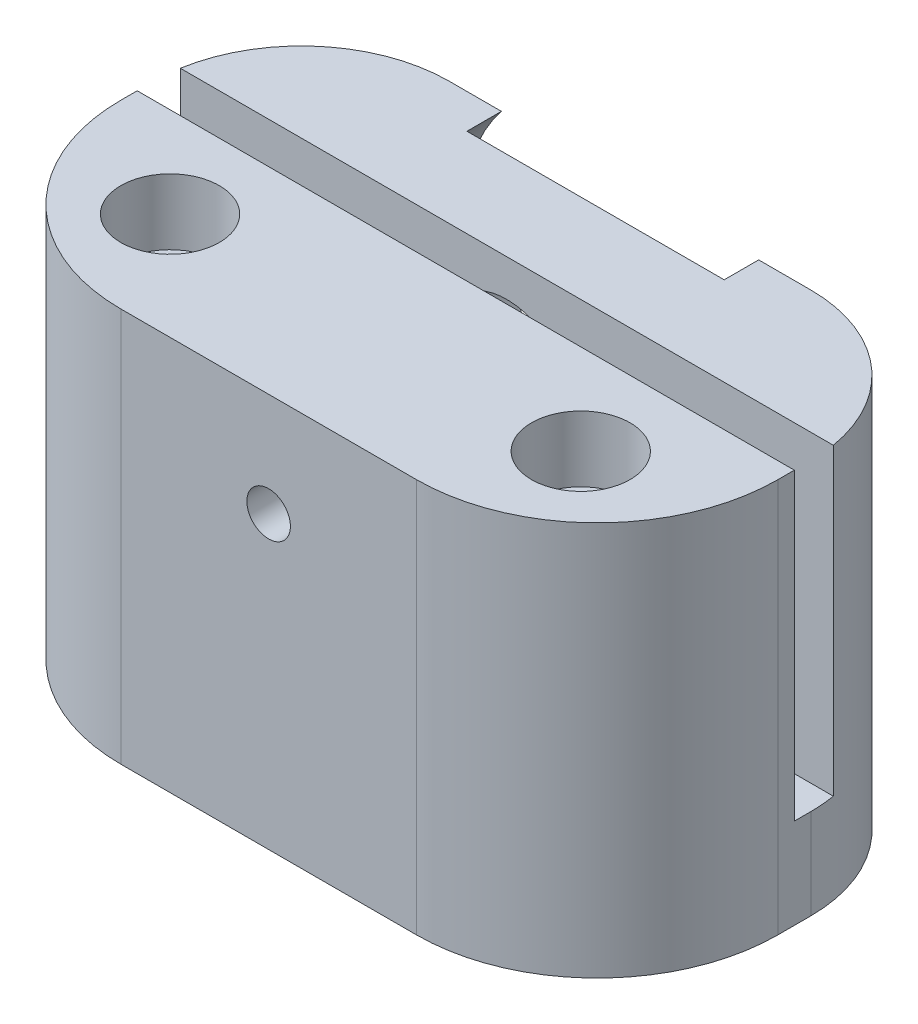
from build123d import *

# Parameters (mm, degrees)
SKETCH2_W                                          = 40
SKETCH2_H                                          = 12
BOSS_EXTRUDE1_DEPTH                                = 24
CBORE_FOR_M2_5_HEX_HEAD_MACHINE_SCREW1_D           = 3
CBORE_FOR_M2_5_HEX_HEAD_MACHINE_SCREW1_DEPTH       = 38.1
CBORE_FOR_M2_5_HEX_HEAD_MACHINE_SCREW1_CBORE_D     = 6
CBORE_FOR_M2_5_HEX_HEAD_MACHINE_SCREW1_CBORE_DEPTH = 4
CBORE_FOR_M2_5_HEX_HEAD_MACHINE_SCREW1_TIP         = 0.901290929
SKETCH11_W                                         = 40
SKETCH11_H                                         = 5.5
BOSS_EXTRUDE2_DEPTH                                = 10
SKETCH12_W                                         = 40
SKETCH12_H                                         = 7.5
BOSS_EXTRUDE3_DEPTH                                = 18.5
SKETCH10_R                                         = 4.05
CUT_EXTRUDE1_DEPTH                                 = 17
CUT_EXTRUDE1_DEPTH_BACK                            = 6
SKETCH13_R                                         = 4.8
CUT_EXTRUDE2_DEPTH                                 = 5.5
SKETCH14_R                                         = 10.05
CUT_EXTRUDE3_DEPTH                                 = 2.1
TAP_DRILL_FOR_M2_5_HELICOIL1_D                     = 2.65
FILLET1_R                                          = 11
FILLET2_R                                          = 9


with BuildPart() as part:
    # Sketch2 → Boss-Extrude1 (new body)
    with BuildSketch(Plane(origin=(0, 0, 0), x_dir=(1, 0, 0), z_dir=(0, 1, 0))):
        with Locations((20, 6)):
            Rectangle(SKETCH2_W, SKETCH2_H)
    extrude(amount=BOSS_EXTRUDE1_DEPTH)

    # CBORE for M2.5 Hex Head Machine Screw1
    with Locations(Plane(origin=(0, 24, 0), x_dir=(1, 0, 0), z_dir=(0, 1, 0))):
        with Locations((7.5, 6.5), (32.5, 6.5)):
            CounterBoreHole(CBORE_FOR_M2_5_HEX_HEAD_MACHINE_SCREW1_D / 2, CBORE_FOR_M2_5_HEX_HEAD_MACHINE_SCREW1_CBORE_D / 2, CBORE_FOR_M2_5_HEX_HEAD_MACHINE_SCREW1_CBORE_DEPTH, depth=CBORE_FOR_M2_5_HEX_HEAD_MACHINE_SCREW1_DEPTH)
            with Locations((0, 0, -(CBORE_FOR_M2_5_HEX_HEAD_MACHINE_SCREW1_DEPTH + CBORE_FOR_M2_5_HEX_HEAD_MACHINE_SCREW1_TIP / 2))):  # 118° drill point
                Cone(0, CBORE_FOR_M2_5_HEX_HEAD_MACHINE_SCREW1_D / 2, CBORE_FOR_M2_5_HEX_HEAD_MACHINE_SCREW1_TIP, mode=Mode.SUBTRACT)

    # Sketch11 → Boss-Extrude2 (add)
    with BuildSketch(Plane(origin=(0, 0, -12), x_dir=(-1, 0, 0), z_dir=(0, 0, -1))):
        with Locations((-20, 2.75)):
            Rectangle(SKETCH11_W, SKETCH11_H)
    extrude(amount=BOSS_EXTRUDE2_DEPTH)

    # Sketch12 → Boss-Extrude3 (add)
    with BuildSketch(Plane(origin=(0, 5.5, 0), x_dir=(1, 0, 0), z_dir=(0, 1, 0))):
        with Locations((20, 18.25)):
            Rectangle(SKETCH12_W, SKETCH12_H)
    extrude(amount=BOSS_EXTRUDE3_DEPTH)

    # Sketch10 → Cut-Extrude1 (cut, two sides)
    with BuildSketch(Plane(origin=(0, 0, -12), x_dir=(-1, 0, 0), z_dir=(0, 0, -1))) as cut_extrude1_sk:
        with Locations((-20, 17.7)):
            Circle(SKETCH10_R)
    extrude(amount=CUT_EXTRUDE1_DEPTH, mode=Mode.SUBTRACT)
    extrude(cut_extrude1_sk.sketch, amount=-CUT_EXTRUDE1_DEPTH_BACK, mode=Mode.SUBTRACT)

    # Sketch13 → Cut-Extrude2 (cut)
    with BuildSketch(Plane(origin=(0, 0, -22), x_dir=(-1, 0, 0), z_dir=(0, 0, -1))):
        with Locations((-20, 17.7)):
            Circle(SKETCH13_R)
    extrude(amount=-CUT_EXTRUDE2_DEPTH, mode=Mode.SUBTRACT)

    # Sketch14 → Cut-Extrude3 (cut)
    with BuildSketch(Plane(origin=(0, 0, -22), x_dir=(-1, 0, 0), z_dir=(0, 0, -1))):
        with Locations((-20, 17.7)):
            Circle(SKETCH14_R)
    extrude(amount=-CUT_EXTRUDE3_DEPTH, mode=Mode.SUBTRACT)

    # Tap Drill for M2.5 Helicoil1 (through all)
    with Locations(Plane(origin=(0, 0, -6), x_dir=(-1, 0, 0), z_dir=(0, 0, -1))):
        with Locations((-20, 17.7)):
            Hole(TAP_DRILL_FOR_M2_5_HELICOIL1_D / 2)

    # Fillet1
    fillet1_edges = [part.edges().sort_by_distance(p)[0] for p in [
        (40, 12, 0),
        (0, 12, 0),
    ]]
    fillet(fillet1_edges, radius=FILLET1_R)

    # Fillet2
    fillet2_edges = [part.edges().sort_by_distance(p)[0] for p in [
        (0, 12, -22),
        (40, 12, -22),
    ]]
    fillet(fillet2_edges, radius=FILLET2_R)


solid = part.part
